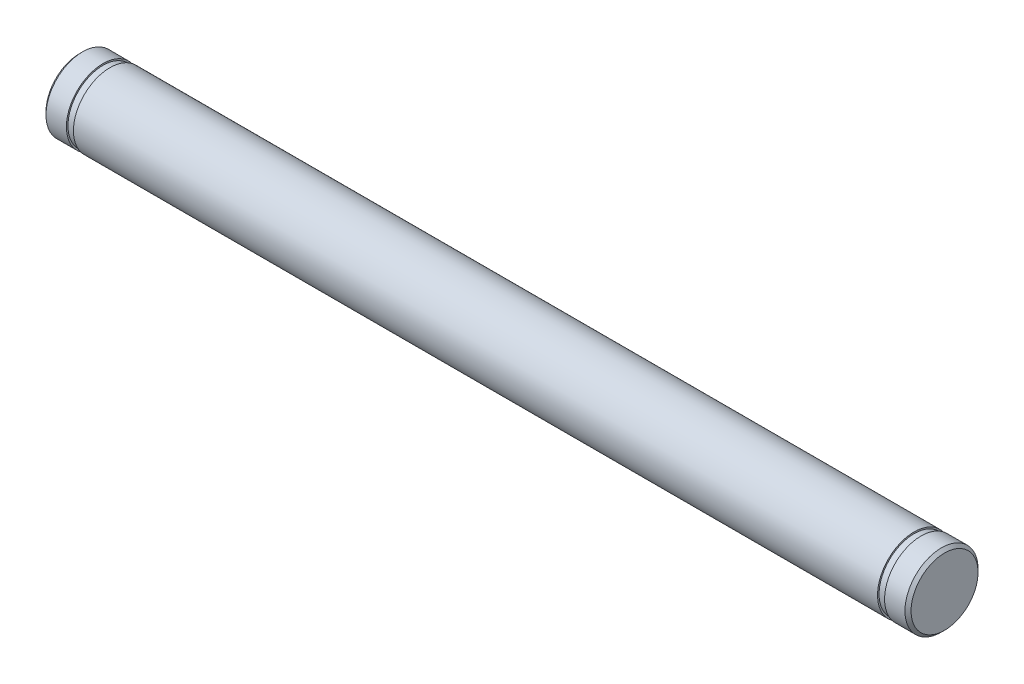
from build123d import *

# Parameters (mm, degrees)
SKETCH_2_R          = 12
SKETCH_2_R_2        = 5.75
CUT_EXTRUDE_1_DEPTH = 1.15
SKETCH_3_R          = 12
SKETCH_3_R_2        = 5.75
CUT_EXTRUDE_2_DEPTH = 1.15


with BuildPart() as part:
    # ｽｹｯﾁ1 → 回転1 (revolve)
    with BuildSketch(Plane.XY):
        Polygon((0, 0), (0, 5.5), (0.5, 6), (141.5, 6), (142, 5.5), (142, 0), align=None)
    revolve(axis=Axis((142, 0, 0), (-1, 0, 0)))

    # ｽｹｯﾁ2 → ｶｯﾄ - 押し出し1 (cut)
    with BuildSketch(Plane(origin=(5, 0, 0), x_dir=(0, 0, -1), z_dir=(1, 0, 0))):
        Circle(SKETCH_2_R)
        Circle(SKETCH_2_R_2, mode=Mode.SUBTRACT)
    extrude(amount=-CUT_EXTRUDE_1_DEPTH, mode=Mode.SUBTRACT)

    # ｽｹｯﾁ3 → ｶｯﾄ - 押し出し2 (cut)
    with BuildSketch(Plane(origin=(137, 0, 0), x_dir=(0, 0, -1), z_dir=(1, 0, 0))):
        Circle(SKETCH_3_R)
        Circle(SKETCH_3_R_2, mode=Mode.SUBTRACT)
    extrude(amount=CUT_EXTRUDE_2_DEPTH, mode=Mode.SUBTRACT)


solid = part.part
